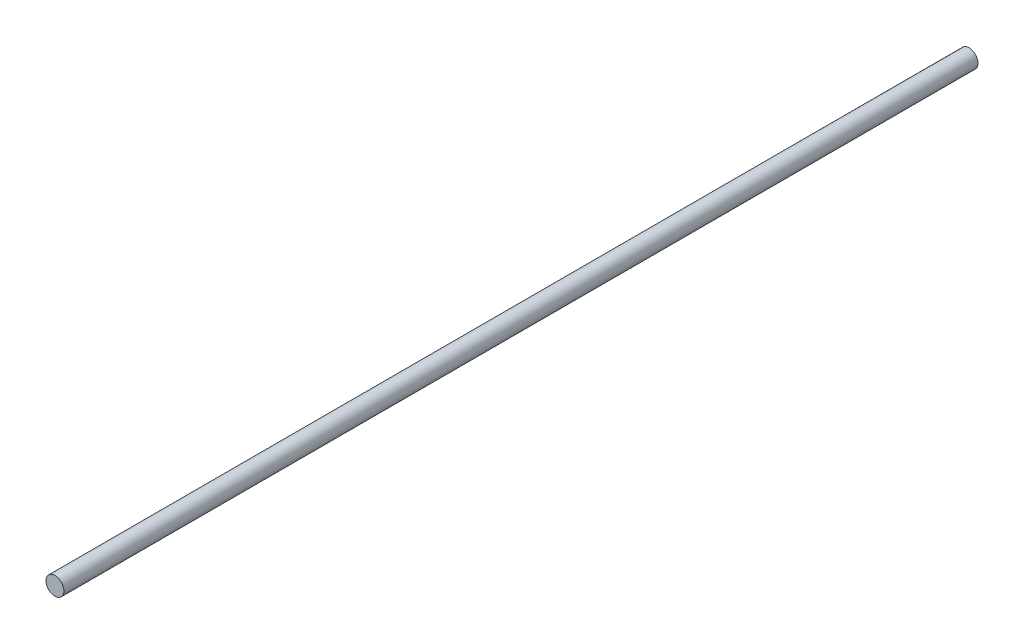
from build123d import *

# Parameters (mm, degrees)
SKETCH1_R           = 5
BOSS_EXTRUDE4_DEPTH = 510


with BuildPart() as part:
    # Sketch1 → Boss-Extrude4 (new body)
    with BuildSketch(Plane.XY):
        Circle(SKETCH1_R)
    extrude(amount=BOSS_EXTRUDE4_DEPTH)


solid = part.part
